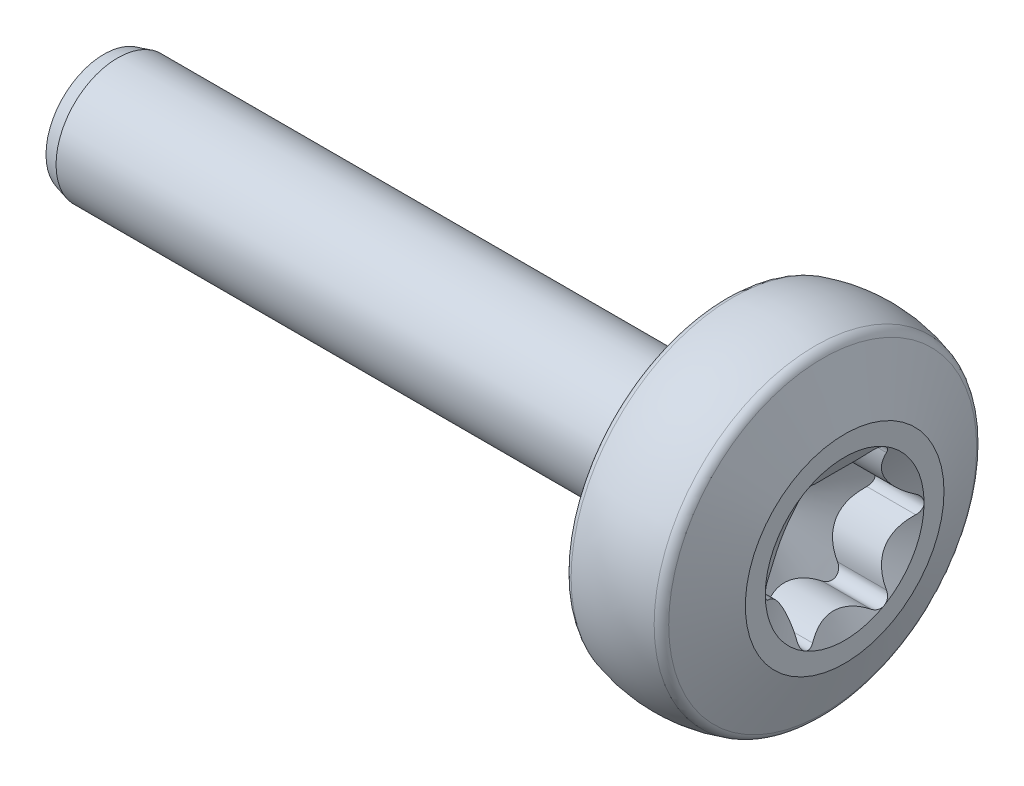
from build123d import *

# Parameters (mm, degrees)
BOSS_EXTRUDE1_REACH = 17.92
SKETCH3_R           = 2.0335875
FILLET1_R           = 0.24638
CHAMFER1_SIZE       = 0.280736842
CHAMFER1_SIZE2      = 0.07522321


with BuildPart() as part:
    # Sketch2 → Revolve1 (revolve)
    with BuildSketch(Plane.XY):
        with BuildLine():
            Line((-7.5819, 0), (7.5819, 0))
            Line((7.5819, 0), (7.5819, 2.0335875))
            Line((7.5819, 2.0335875), (7.08914, 3.25755))
            ThreePointArc((7.08914, 3.25755), (6.10362, 3.429), (5.1181, 3.25755))
            Line((5.1181, 3.25755), (5.1181, 2.003369298))
            ThreePointArc((5.1181, 2.003369298), (5.106940768, 1.97642853), (5.08, 1.965269298))
            ThreePointArc((5.08, 1.965269298), (5.053059232, 1.954110067), (5.0419, 1.927169298))
            Line((5.0419, 1.927169298), (5.0419, 1.261978947))
            Line((5.0419, 1.261978947), (-7.5819, 1.261978947))
            Line((-7.5819, 1.261978947), (-7.5819, 0))
        make_face()
    revolve(axis=Axis((-7.5819, 0, 0), (-1, 0, 0)))

    # Sketch12 → Cut-Revolve3 (revolve, cut)
    with BuildSketch(Plane.XY):
        Polygon((7.5819, 1.6256), (6.58098125, 1.6256), (5.642440652, 0), (7.5819, 0), align=None)
    revolve(axis=Axis((-7.5819, 0, 0), (1, 0, 0)), mode=Mode.SUBTRACT)

    # Boss-Extrude1: up to this cone (the profile starts inside it)
    boss_extrude1_end = Plane(origin=(7.5819, 0, 0), z_dir=(1, 0, 0)).offset(-1.939458348) * Cone(1.732e-06, 41.081996047, 23.718700477, align=(Align.CENTER, Align.CENTER, Align.MIN), mode=Mode.PRIVATE)
    # Sketch3 → Boss-Extrude1 (add, up to the surface)
    with BuildSketch(Plane(origin=(7.5819, 0, 0), x_dir=(0, 0, -1), z_dir=(1, 0, 0)), mode=Mode.PRIVATE) as boss_extrude1_sk1:
        Circle(SKETCH3_R)
        with BuildLine():
            ThreePointArc((1.51222877, -0.182266377), (1.594944844, -0.107324354), (1.6256, 0))
            ThreePointArc((1.6256, 0), (1.594944844, 0.107324354), (1.51222877, 0.182266377))
            ThreePointArc((1.51222877, 0.182266377), (1.055858172, 0.6096), (0.913961698, 1.218495343))
            ThreePointArc((0.913961698, 1.218495343), (0.890418039, 1.327600575), (0.8128, 1.407810896))
            ThreePointArc((0.8128, 1.407810896), (0.704526805, 1.434924929), (0.598267073, 1.40076172))
            ThreePointArc((0.598267073, 1.40076172), (0, 1.2192), (-0.598267073, 1.40076172))
            ThreePointArc((-0.598267073, 1.40076172), (-0.704526805, 1.434924929), (-0.8128, 1.407810896))
            ThreePointArc((-0.8128, 1.407810896), (-0.890418039, 1.327600575), (-0.913961698, 1.218495343))
            ThreePointArc((-0.913961698, 1.218495343), (-1.055858172, 0.6096), (-1.51222877, 0.182266377))
            ThreePointArc((-1.51222877, 0.182266377), (-1.594944844, 0.107324354), (-1.6256, 0))
            ThreePointArc((-1.6256, 0), (-1.594944844, -0.107324354), (-1.51222877, -0.182266377))
            ThreePointArc((-1.51222877, -0.182266377), (-1.055858172, -0.6096), (-0.913961698, -1.218495343))
            ThreePointArc((-0.913961698, -1.218495343), (-0.890418039, -1.327600575), (-0.8128, -1.407810896))
            ThreePointArc((-0.8128, -1.407810896), (-0.704526805, -1.434924929), (-0.598267073, -1.40076172))
            ThreePointArc((-0.598267073, -1.40076172), (0, -1.2192), (0.598267073, -1.40076172))
            ThreePointArc((0.598267073, -1.40076172), (0.704526805, -1.434924929), (0.8128, -1.407810896))
            ThreePointArc((0.8128, -1.407810896), (0.890418039, -1.327600575), (0.913961698, -1.218495343))
            ThreePointArc((0.913961698, -1.218495343), (1.055858172, -0.6096), (1.51222877, -0.182266377))
        make_face(mode=Mode.SUBTRACT)
    boss_extrude1_tool1 = extrude(boss_extrude1_sk1.sketch, amount=-BOSS_EXTRUDE1_REACH, mode=Mode.PRIVATE) & boss_extrude1_end
    add(boss_extrude1_tool1.solids().sort_by_distance((7.5819, 0, 1.976069))[0])

    # Cut-Extrude2 cone 1 section (through the dimple's axis) → Cut-Extrude2 (revolve, cut)
    with BuildSketch(Plane(origin=(7.5819, 0, 0), x_dir=(0, 0, -1), z_dir=(0, 1, 0))):
        Polygon((0, 0), (1.6256, 0), (0, 0.938540598), align=None)
    revolve(axis=Axis((7.5819, 0, 0), (-1, 0, 0)), mode=Mode.SUBTRACT)

    # Fillet1
    fillet1_edges = [part.edges().sort_by_distance(p)[0] for p in [
        (5.1181, -3.25755, 0),
        (7.08914, -3.25755, 0),
    ]]
    fillet(fillet1_edges, radius=FILLET1_R)

    # Chamfer1
    chamfer1_edges = [part.edges().sort_by_distance(p)[0] for p in [
        (-7.5819, -1.261978947, 0),
    ]]
    chamfer1_side = [part.faces().sort_by_distance(p)[0] for p in [
        (-1.27, -1.261978947, 0),
    ]]
    chamfer(chamfer1_edges, length=CHAMFER1_SIZE, length2=CHAMFER1_SIZE2, reference=chamfer1_side[0])


solid = part.part
